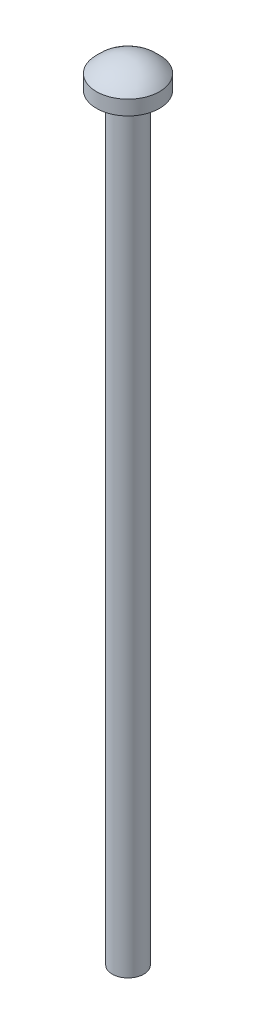
from build123d import *


with BuildPart() as part:
    # Sketch3 → Revolve3 (revolve)
    with BuildSketch(Plane(origin=(0, 0, 0), x_dir=(0, 0, -1), z_dir=(1, 0, 0))):
        with BuildLine():
            Line((0, -49.399528775), (-1.5875, -49.399528775))
            Line((-1.5875, -49.399528775), (-1.5875, 26.800471225))
            Line((-1.5875, 26.800471225), (-3.175, 26.800471225))
            Line((-3.175, 26.800471225), (-3.175, 28.263416417))
            ThreePointArc((-3.175, 28.263416417), (-1.747915447, 29.343035373), (0, 29.726361609))
            Line((0, 29.726361609), (0, -49.399528775))
        make_face()
    revolve(axis=Axis((0, -49.399528775, 0), (0, 1, 0)))


solid = part.part
